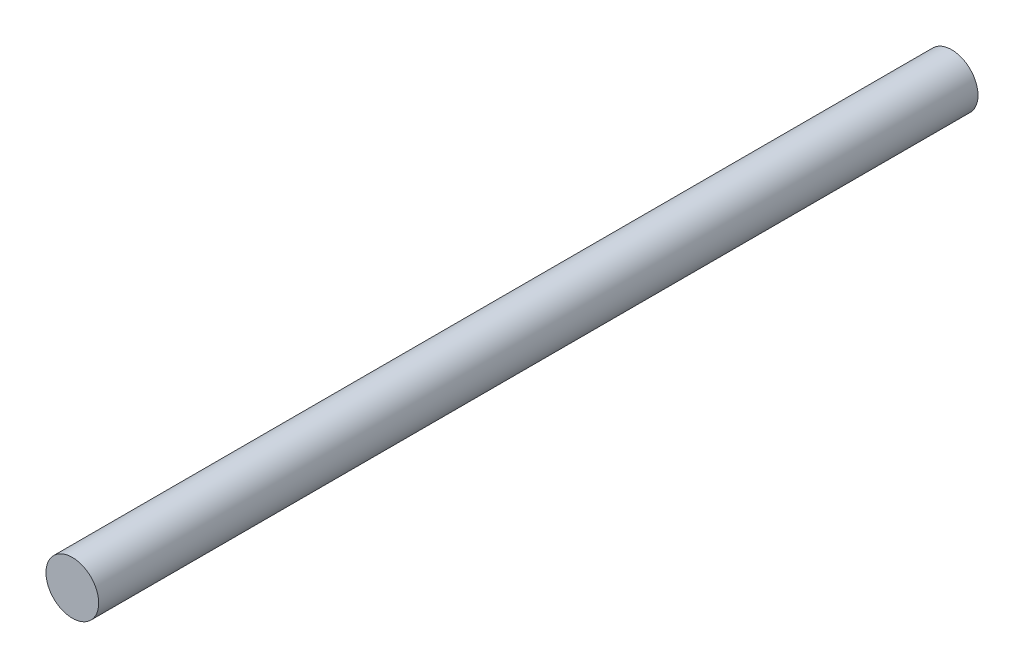
from build123d import *

# Parameters (mm, degrees)
SKETCH1_R           = 7.5
BOSS_EXTRUDE1_DEPTH = 250
SCALE1_SCALE        = 10
SCALE2_SCALE        = 0.75


with BuildPart() as part:
    # Sketch1 → Boss-Extrude1 (new body)
    with BuildSketch(Plane.XY):
        Circle(SKETCH1_R)
    extrude(amount=BOSS_EXTRUDE1_DEPTH)


with BuildPart() as part_1:
    # Scale1: scaled about (0, 0, 125)
    add(part.part.scale(SCALE1_SCALE).moved(Location((0, 0, -1125))))


with BuildPart() as part_2:
    # Scale2: scaled about (0, 0, 0)
    add(part_1.part.scale(SCALE2_SCALE))


solid = part_2.part
